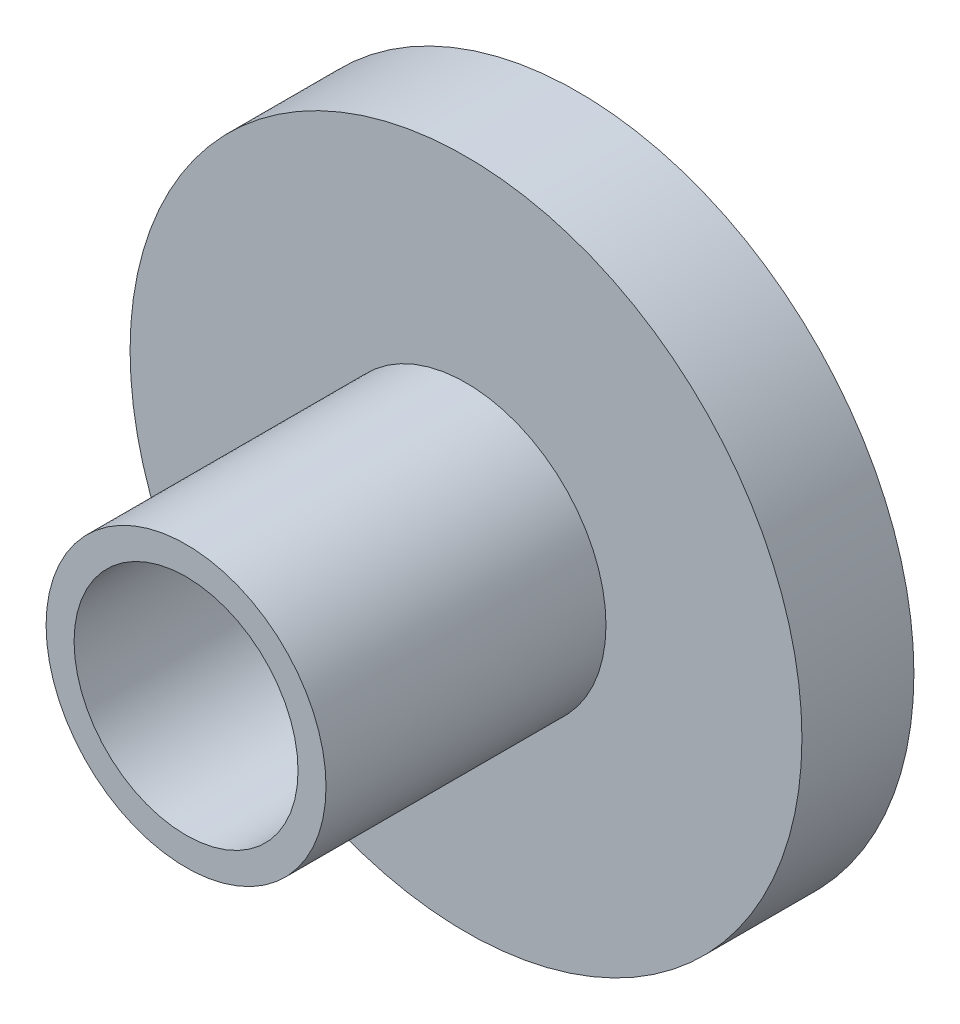
from build123d import *

# Parameters (mm, degrees)
SKETCH_1_R      = 6
EXTRUDE_1_DEPTH = 2
SKETCH_2_R      = 2.5
SKETCH_2_R_2    = 2
EXTRUDE_2_DEPTH = 5


with BuildPart() as part:
    # 草图1 → 凸台-拉伸1 (new body)
    with BuildSketch(Plane.XY):
        Circle(SKETCH_1_R)
    extrude(amount=EXTRUDE_1_DEPTH)

    # 草图2 → 凸台-拉伸2 (add)
    with BuildSketch(Plane.XY.offset(2)):
        Circle(SKETCH_2_R)
        Circle(SKETCH_2_R_2, mode=Mode.SUBTRACT)
    extrude(amount=EXTRUDE_2_DEPTH)


solid = part.part
